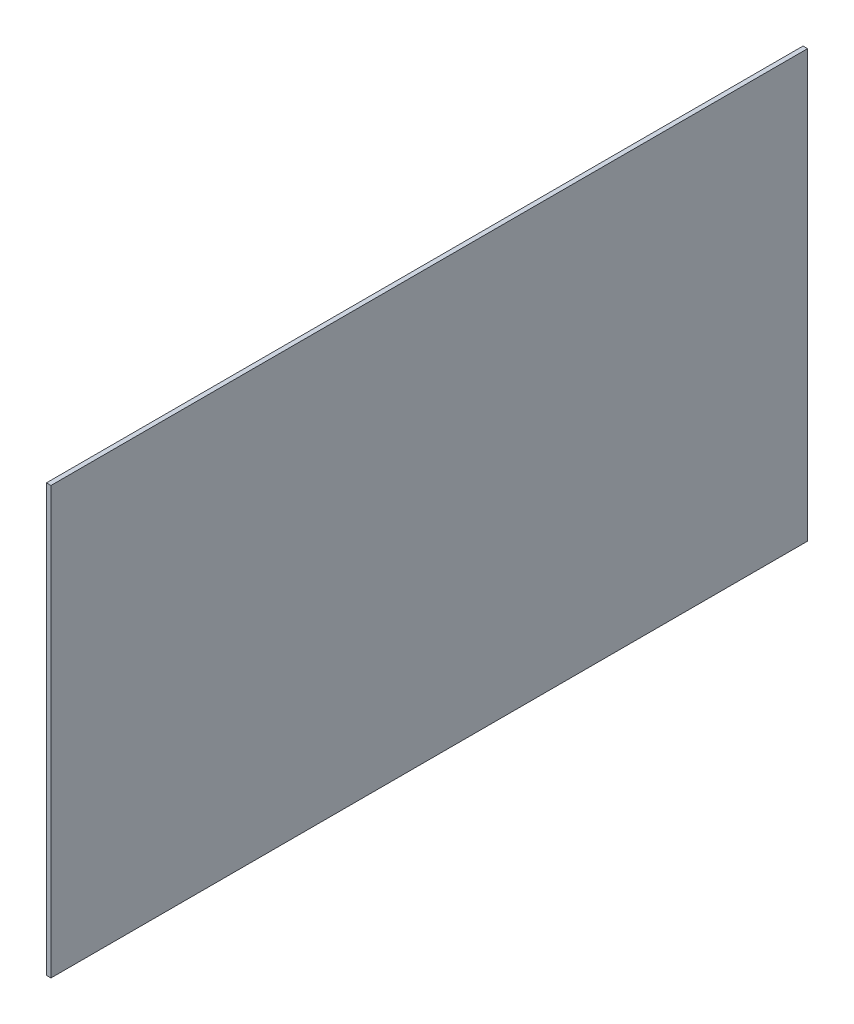
from build123d import *

# Parameters (mm, degrees)
SKETCH1_W           = 500
SKETCH1_H           = 281.86087068
BOSS_EXTRUDE1_DEPTH = 3


with BuildPart() as part:
    # Sketch1 → Boss-Extrude1 (new body)
    with BuildSketch(Plane(origin=(0, 0, 0), x_dir=(0, 0, -1), z_dir=(1, 0, 0))):
        Rectangle(SKETCH1_W, SKETCH1_H)
    extrude(amount=BOSS_EXTRUDE1_DEPTH)


solid = part.part
